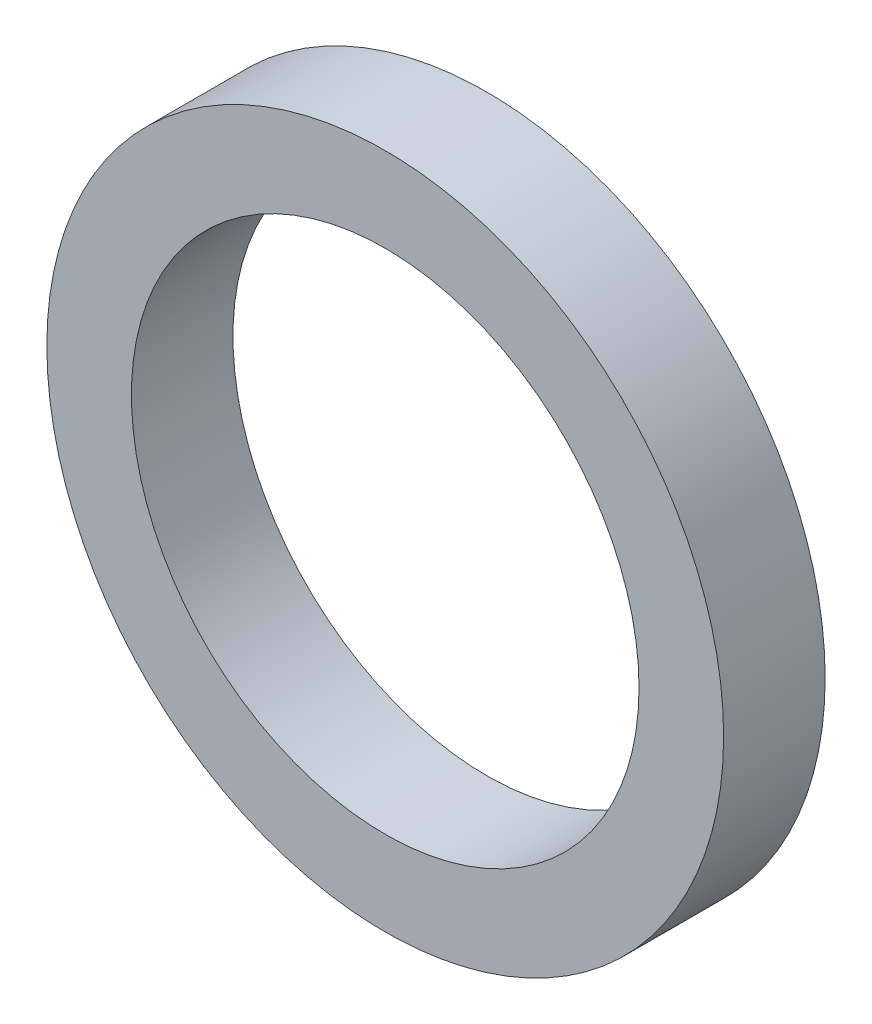
from build123d import *

# Parameters (mm, degrees)
SKETCH_1_R      = 4
SKETCH_1_R_2    = 3
EXTRUDE_1_DEPTH = 1.2


with BuildPart() as part:
    # 草图1 → 凸台-拉伸1 (new body)
    with BuildSketch(Plane.XY):
        Circle(SKETCH_1_R)
        Circle(SKETCH_1_R_2, mode=Mode.SUBTRACT)
    extrude(amount=EXTRUDE_1_DEPTH)


solid = part.part
